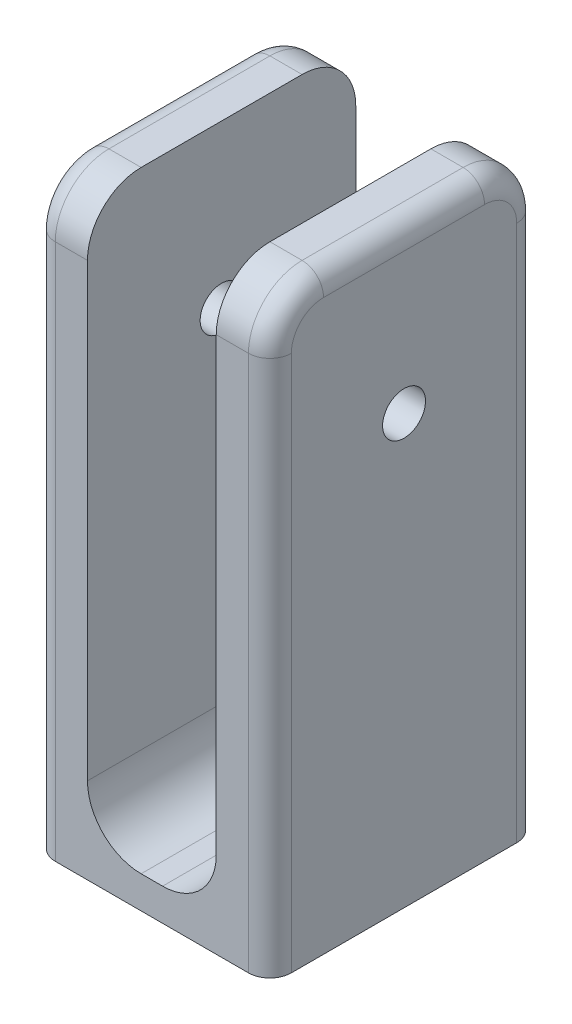
from build123d import *

# Parameters (mm, degrees)
SKETCH1_W             = 12
SKETCH1_H             = 25
BOSS_EXTRUDE1_DEPTH   = 3
SKETCH1_3_W           = 5
SKETCH1_3_H           = 25
BOSS_EXTRUDE2_DEPTH   = 55
FILLET1_R             = 5
FILLET2_R             = 2
F_4_0MM_DOWEL_HOLE3_D = 4


with BuildPart() as part:
    # Sketch1 → Boss-Extrude1 (new body)
    with BuildSketch(Plane(origin=(0, 0, 0), x_dir=(1, 0, 0), z_dir=(0, 1, 0))):
        Rectangle(SKETCH1_W, SKETCH1_H)
    extrude(amount=BOSS_EXTRUDE1_DEPTH)

    # Sketch1_3 → Boss-Extrude2 (add)
    with BuildSketch(Plane(origin=(0, 0, 0), x_dir=(1, 0, 0), z_dir=(0, 1, 0))):
        with Locations((8.5, 0)):
            Rectangle(SKETCH1_3_W, SKETCH1_3_H)
        with Locations((-8.5, 0)):
            Rectangle(SKETCH1_3_W, SKETCH1_3_H)
    extrude(amount=BOSS_EXTRUDE2_DEPTH)

    # Fillet1
    fillet1_edges = [part.edges().sort_by_distance(p)[0] for p in [
        (8.5, 55, -12.5),
        (-8.5, 55, -12.5),
        (-8.5, 55, 12.5),
        (8.5, 55, 12.5),
        (6, 3, 0),
        (-6, 3, 0),
    ]]
    fillet(fillet1_edges, radius=FILLET1_R)

    # Fillet2
    fillet2_edges = [part.edges().sort_by_distance(p)[0] for p in [
        (-11, 25, -12.5),
        (-11, 53.535533906, -11.035533906),
        (-11, 55, 0),
        (-11, 53.535533906, 11.035533906),
        (11, 25, -12.5),
        (11, 53.535533906, -11.035533906),
        (11, 55, 0),
        (11, 53.535533906, 11.035533906),
        (-11, 25, 12.5),
        (11, 25, 12.5),
    ]]
    fillet(fillet2_edges, radius=FILLET2_R)

    # Ø4.0mm Dowel Hole3 (through all)
    with Locations(Plane.ZY.offset(11)):
        with Locations((0, 39.901131087)):
            Hole(F_4_0MM_DOWEL_HOLE3_D / 2)


solid = part.part
